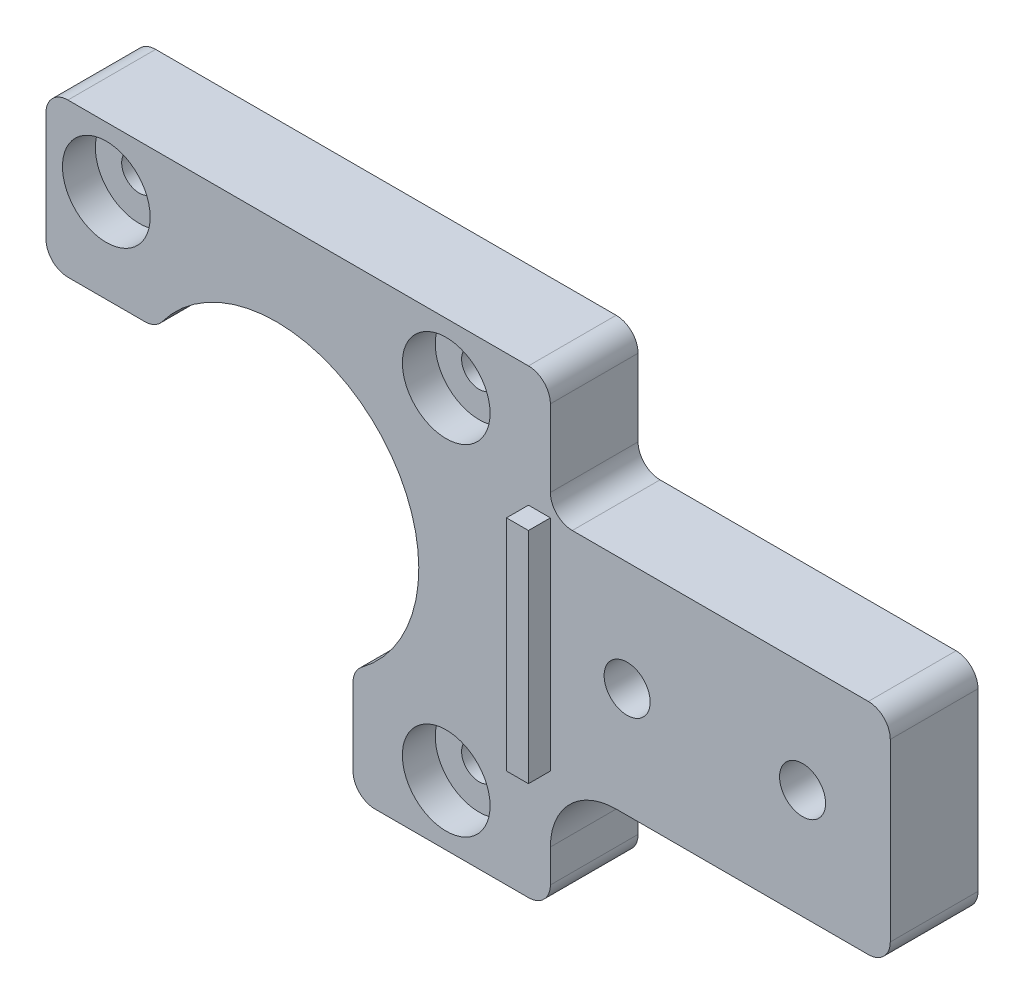
from build123d import *

# Parameters (mm, degrees)
ESQUISSE1_W             = 77
ESQUISSE1_H             = 42
BOSS_EXTRU_1_DEPTH      = 8
ESQUISSE3_R             = 4
ENL_V_MAT_EXTRU_1_DEPTH = 3
ESQUISSE4_R             = 13
ENL_V_MAT_EXTRU_2_DEPTH = 9
ESQUISSE5_W             = 28
ESQUISSE5_H             = 28
ENL_V_MAT_EXTRU_3_DEPTH = 9
ESQUISSE10_R            = 1.6
ENL_V_MAT_EXTRU_4_DEPTH = 6
ESQUISSE11_W            = 31
ESQUISSE11_H            = 11
ENL_V_MAT_EXTRU_5_DEPTH = 9
ESQUISSE12_R            = 2.1
ENL_V_MAT_EXTRU_6_DEPTH = 9
CONG_1_R                = 6
CONG_2_R                = 2
SKETCH1_W               = 2
SKETCH1_H               = 20
BOSS_EXTRUDE1_DEPTH     = 2


with BuildPart() as part:
    # Esquisse1 → Boss.-Extru.1 (new body)
    with BuildSketch(Plane.XY):
        with Locations((38.5, 21)):
            Rectangle(ESQUISSE1_W, ESQUISSE1_H)
    extrude(amount=BOSS_EXTRU_1_DEPTH)

    # Esquisse3 → Enlèv. mat.-Extru.1 (cut)
    with BuildSketch(Plane.XY.offset(8)):
        with Locations((5.5, 36.5)):
            Circle(ESQUISSE3_R)
        with Locations((36.5, 36.5)):
            Circle(ESQUISSE3_R)
        with Locations((36.5, 5.5)):
            Circle(ESQUISSE3_R)
    extrude(amount=-ENL_V_MAT_EXTRU_1_DEPTH, mode=Mode.SUBTRACT)

    # Esquisse4 → Enlèv. mat.-Extru.2 (cut, through all)
    with BuildSketch(Plane.XY.offset(8)):
        with Locations((21, 21)):
            Circle(ESQUISSE4_R)
    extrude(amount=-ENL_V_MAT_EXTRU_2_DEPTH, mode=Mode.SUBTRACT)

    # Esquisse5 → Enlèv. mat.-Extru.3 (cut, through all)
    with BuildSketch(Plane.XY.offset(8)):
        with Locations((14, 14)):
            Rectangle(ESQUISSE5_W, ESQUISSE5_H)
    extrude(amount=-ENL_V_MAT_EXTRU_3_DEPTH, mode=Mode.SUBTRACT)

    # Esquisse10 → Enlèv. mat.-Extru.4 (cut, through all)
    with BuildSketch(Plane.XY.offset(5)):
        with Locations((5.5, 36.5)):
            Circle(ESQUISSE10_R)
        with Locations((36.5, 36.5)):
            Circle(ESQUISSE10_R)
        with Locations((36.5, 5.5)):
            Circle(ESQUISSE10_R)
    extrude(amount=-ENL_V_MAT_EXTRU_4_DEPTH, mode=Mode.SUBTRACT)

    # Esquisse11 → Enlèv. mat.-Extru.5 (cut, through all)
    with BuildSketch(Plane.XY.offset(8)):
        with Locations((61.5, 5.5)):
            Rectangle(ESQUISSE11_W, ESQUISSE11_H)
        with Locations((61.5, 36.5)):
            Rectangle(ESQUISSE11_W, ESQUISSE11_H)
    extrude(amount=-ENL_V_MAT_EXTRU_5_DEPTH, mode=Mode.SUBTRACT)

    # Esquisse12 → Enlèv. mat.-Extru.6 (cut, through all)
    with BuildSketch(Plane.XY.offset(8)):
        with Locations((53, 21)):
            Circle(ESQUISSE12_R)
        with Locations((69, 21)):
            Circle(ESQUISSE12_R)
    extrude(amount=-ENL_V_MAT_EXTRU_6_DEPTH, mode=Mode.SUBTRACT)

    # Congé1
    cong_1_edges = [part.edges().sort_by_distance(p)[0] for p in [
        (46, 11, 4),
    ]]
    fillet(cong_1_edges, radius=CONG_1_R)

    # Congé2
    cong_2_edges = [part.edges().sort_by_distance(p)[0] for p in [
        (28, 10.04554885, 4),
        (10.04554885, 28, 4),
        (0, 28, 4),
        (28, 0, 4),
        (77, 11, 4),
        (46, 0, 4),
        (0, 42, 4),
        (77, 31, 4),
        (46, 31, 4),
        (46, 42, 4),
    ]]
    fillet(cong_2_edges, radius=CONG_2_R)

    # Sketch1 → Boss-Extrude1 (add)
    with BuildSketch(Plane.XY.offset(8)):
        with Locations((45, 21)):
            Rectangle(SKETCH1_W, SKETCH1_H)
    extrude(amount=BOSS_EXTRUDE1_DEPTH)


solid = part.part
